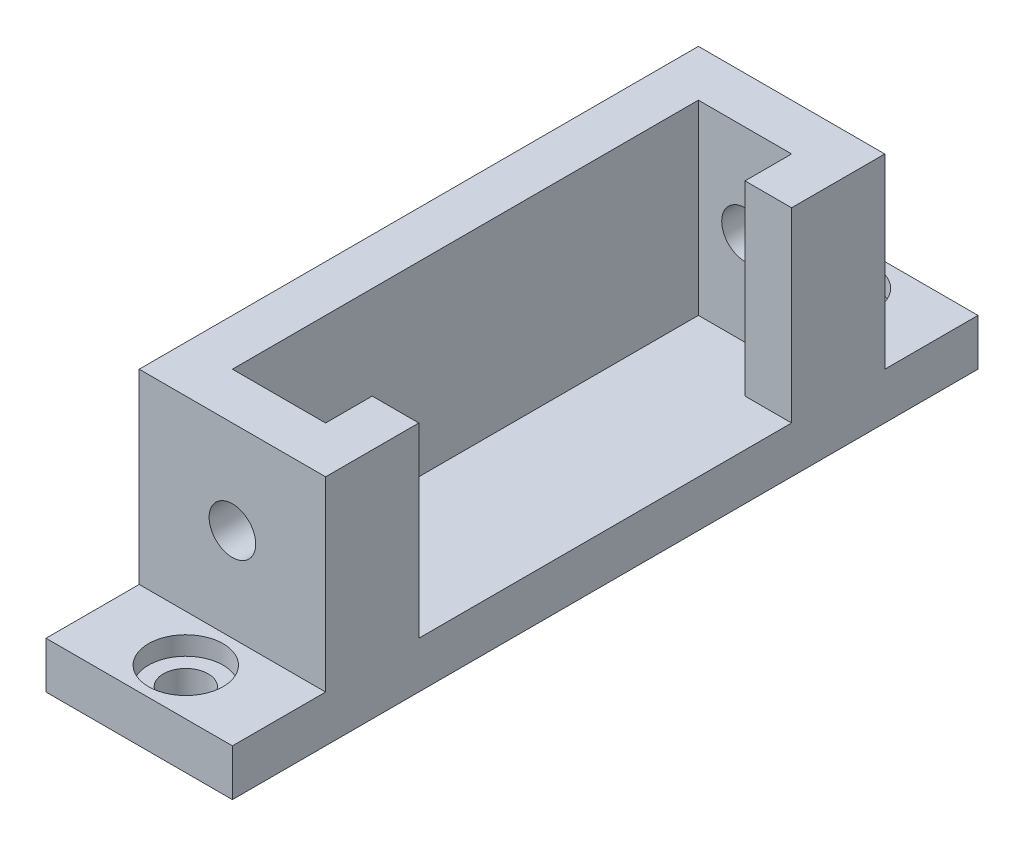
from build123d import *

# Parameters (mm, degrees)
BOSS_EXTRU_1_DEPTH                                = 60
ENL_V_MAT_EXTRU_1_DEPTH                           = 20
ENL_V_MAT_EXTRU_2_DEPTH                           = 69.174115585
ENL_V_MAT_EXTRU_2_DEPTH_BACK                      = 69.174115585
ESQUISSE3_R                                       = 2.5
BOSS_EXTRU_2_DEPTH                                = 10
CHAMBRAGE_POUR_VIS_SIX_PANS_CREUX_M41_D           = 4.8
CHAMBRAGE_POUR_VIS_SIX_PANS_CREUX_M41_CBORE_D     = 8
CHAMBRAGE_POUR_VIS_SIX_PANS_CREUX_M41_CBORE_DEPTH = 2


with BuildPart() as part:
    # Esquisse1 → Boss.-Extru.1 (new body)
    with BuildSketch(Plane.XY):
        with BuildLine():
            Line((-19.942668722, 35), (-19.942668722, 10))
            Line((-19.942668722, 10), (-12.342668722, 10))
            Line((-12.342668722, 10), (-12.342668722, 8))
            ThreePointArc((-12.342668722, 8), (-9.942668722, 5.6), (-7.542668722, 8))
            Line((-7.542668722, 8), (-7.542668722, 10))
            Line((-7.542668722, 10), (0.057331278, 10))
            Line((0.057331278, 10), (0.057331278, 35))
            Line((0.057331278, 35), (-19.942668722, 35))
        make_face()
    extrude(amount=BOSS_EXTRU_1_DEPTH)

    # Esquisse2 → Enlèv. mat.-Extru.1 (cut)
    with BuildSketch(Plane(origin=(0, 35, 0), x_dir=(1, 0, 0), z_dir=(0, 1, 0))):
        Polygon((0.057331278, -50), (0.057331278, -10), (-4.942668722, -10), (-4.942668722, -5), (-14.942668722, -5), (-14.942668722, -55), (-4.942668722, -55), (-4.942668722, -50), align=None)
    extrude(amount=-ENL_V_MAT_EXTRU_1_DEPTH, mode=Mode.SUBTRACT)

    # Esquisse3 → Enlèv. mat.-Extru.2 (cut, two sides: drawn at the far end of the back side and taken through both)
    with BuildSketch(Plane.XY.offset(5).offset(-ENL_V_MAT_EXTRU_2_DEPTH_BACK)):
        with Locations((-9.942668722, 25)):
            Circle(ESQUISSE3_R)
    extrude(amount=ENL_V_MAT_EXTRU_2_DEPTH + ENL_V_MAT_EXTRU_2_DEPTH_BACK, mode=Mode.SUBTRACT)

    # Esquisse4 → Boss.-Extru.2 (add)
    with BuildSketch(Plane.XY.offset(60)):
        Polygon((-19.942668722, 15), (-19.942668722, 10), (-12.342668722, 10), (-7.542668722, 10), (0.057331278, 10), (0.057331278, 15), align=None)
    boss_extru_2 = extrude(amount=BOSS_EXTRU_2_DEPTH)

    # Symétrie1: Boss.-Extru.2 across plane
    add(boss_extru_2.mirror(Plane.XY.offset(30)))

    # Chambrage pour vis à six pans creux M41 (through all)
    with Locations(Plane(origin=(-9.971334361, 15, -5), x_dir=(0, 0, 1), z_dir=(0, 1, 0))):
        with Locations((0, 0), (70, 0.028665639)):
            CounterBoreHole(CHAMBRAGE_POUR_VIS_SIX_PANS_CREUX_M41_D / 2, CHAMBRAGE_POUR_VIS_SIX_PANS_CREUX_M41_CBORE_D / 2, CHAMBRAGE_POUR_VIS_SIX_PANS_CREUX_M41_CBORE_DEPTH)


solid = part.part
